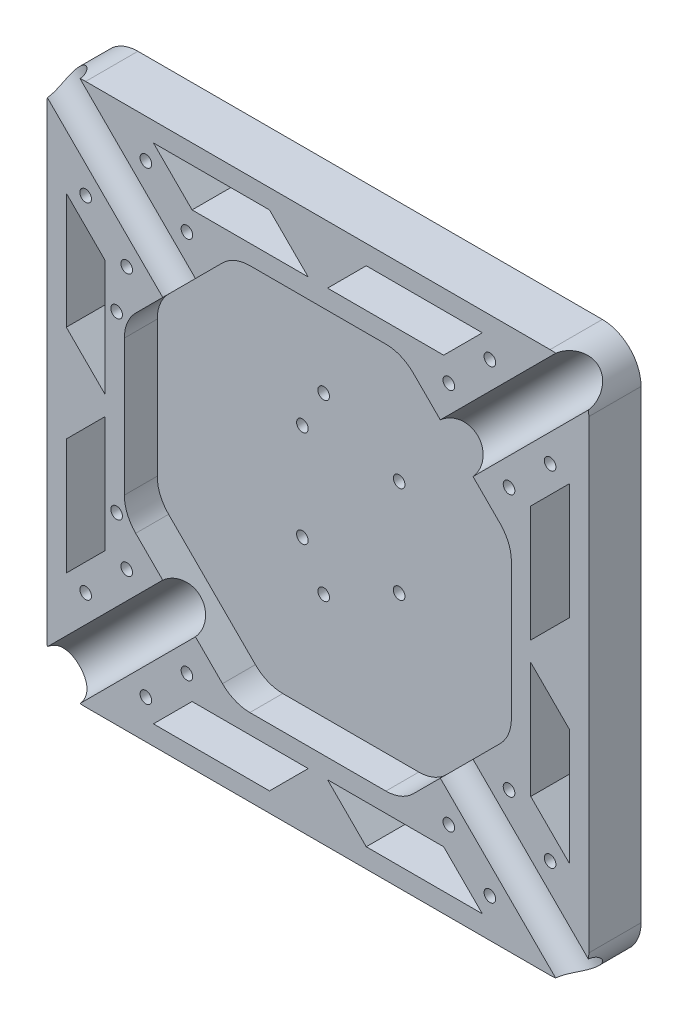
from build123d import *

# Parameters (mm, degrees)
ESQUISSE1_W                  = 140
ESQUISSE1_H                  = 140
BOSS_EXTRU_1_DEPTH           = 13.5
ENL_V_MAT_EXTRU_3_DEPTH      = 8.5
ENL_V_MAT_EXTRU_1_DEPTH      = 100
R_P_TITION_CIRCULAIRE1_COUNT = 2
R_P_TITION_CIRCULAIRE1_ANGLE = 90
CONG_1_R                     = 10
ESQUISSE3_R                  = 1.5
ENL_V_MAT_EXTRU_2_DEPTH      = 13.5
ENL_V_MAT_EXTRU_4_DEPTH      = 10
ENL_V_MAT_EXTRU_4_DEPTH_BACK = 12.5
ESQUISSE5_R                  = 1.5


with BuildPart() as part:
    # Esquisse1 → Boss.-Extru.1 (new body)
    with BuildSketch(Plane.XY):
        Rectangle(ESQUISSE1_W, ESQUISSE1_H)
        Polygon((65, 12.5), (55, 2.5), (55, 32.5), (65, 42.5), align=None, mode=Mode.SUBTRACT)
        Polygon((65, -12.5), (55, -2.5), (55, -32.5), (65, -42.5), align=None, mode=Mode.SUBTRACT)
        Polygon((12.5, -65), (2.5, -55), (32.5, -55), (42.5, -65), align=None, mode=Mode.SUBTRACT)
        Polygon((-12.5, -65), (-2.5, -55), (-32.5, -55), (-42.5, -65), align=None, mode=Mode.SUBTRACT)
        Polygon((-65, -12.5), (-55, -2.5), (-55, -32.5), (-65, -42.5), align=None, mode=Mode.SUBTRACT)
        Polygon((-65, 12.5), (-55, 2.5), (-55, 32.5), (-65, 42.5), align=None, mode=Mode.SUBTRACT)
        Polygon((-12.5, 65), (-2.5, 55), (-32.5, 55), (-42.5, 65), align=None, mode=Mode.SUBTRACT)
        Polygon((12.5, 65), (2.5, 55), (32.5, 55), (42.5, 65), align=None, mode=Mode.SUBTRACT)
    extrude(amount=BOSS_EXTRU_1_DEPTH)

    # Esquisse4 → Enlèv. mat.-Extru.3 (cut)
    with BuildSketch(Plane.XY.offset(13.5)):
        Polygon((-21.715728753, 50), (-50, 21.715728753), (-50, -21.715728753), (-21.715728753, -50), (21.715728753, -50), (50, -21.715728753), (50, 21.715728753), (21.715728753, 50), align=None)
    extrude(amount=-ENL_V_MAT_EXTRU_3_DEPTH, mode=Mode.SUBTRACT)

    # Esquisse2 → Enlèv. mat.-Extru.1 (cut, symmetric)
    with BuildSketch(Plane(origin=(0, 0, 0), x_dir=(-0.7071067811865475, -0.7071067811865477, 0), z_dir=(-0.7071067811865477, 0.7071067811865475, 0))):
        with BuildLine():
            Line((-6, 14), (6, 14))
            ThreePointArc((6, 14), (0, 8), (-6, 14))
        make_face()
    enl_v_mat_extru_1 = extrude(amount=ENL_V_MAT_EXTRU_1_DEPTH, both=True, mode=Mode.SUBTRACT)

    # Répétition circulaire1: Enlèv. mat.-Extru.1 ×2 about axis
    r_p_tition_circulaire1_axis = Axis((0, 0, -62.841973852), (0, 0, 1))
    for i in range(1, R_P_TITION_CIRCULAIRE1_COUNT):
        add(enl_v_mat_extru_1.rotate(r_p_tition_circulaire1_axis, i * R_P_TITION_CIRCULAIRE1_ANGLE / (R_P_TITION_CIRCULAIRE1_COUNT - 1)), mode=Mode.SUBTRACT)

    # Congé1
    cong_1_edges = [part.edges().sort_by_distance(p)[0] for p in [
        (-70, 70, 4),
        (-70, -70, 4),
        (70, 70, 4),
        (70, -70, 4),
        (-21.715728753, -50, 9.25),
        (21.715728753, -50, 9.25),
        (50, -21.715728753, 9.25),
        (50, 21.715728753, 9.25),
        (21.715728753, 50, 9.25),
        (-21.715728753, 50, 9.25),
        (-50, -21.715728753, 9.25),
        (-50, 21.715728753, 9.25),
    ]]
    fillet(cong_1_edges, radius=CONG_1_R)

    # Esquisse3 → Enlèv. mat.-Extru.2 (cut)
    with BuildSketch(Plane.XY.offset(13.5)):
        with Locations((-60, -44.443650814)):
            Circle(ESQUISSE3_R)
        with Locations((-44.443650814, -60)):
            Circle(ESQUISSE3_R)
        with Locations((-44.443650814, 60)):
            Circle(ESQUISSE3_R)
        with Locations((-60, 44.443650814)):
            Circle(ESQUISSE3_R)
        with Locations((60, 44.443650814)):
            Circle(ESQUISSE3_R)
        with Locations((44.443650814, 60)):
            Circle(ESQUISSE3_R)
        with Locations((44.443650814, -60)):
            Circle(ESQUISSE3_R)
        with Locations((60, -44.443650814)):
            Circle(ESQUISSE3_R)
    extrude(amount=-ENL_V_MAT_EXTRU_2_DEPTH, mode=Mode.SUBTRACT)

    # Esquisse5 → Enlèv. mat.-Extru.4 (cut, two sides: drawn at the far end of the back side and taken through both)
    with BuildSketch(Plane.XY.offset(5).offset(-ENL_V_MAT_EXTRU_4_DEPTH_BACK)):
        with Locations((-52, 22.5)):
            Circle(ESQUISSE5_R)
        with Locations((-7.000000025, 22.498488866)):
            Circle(ESQUISSE5_R)
        with Locations((-52.000000025, -22.5)):
            Circle(ESQUISSE5_R)
        with Locations((-7.000000025, -22.501511134)):
            Circle(ESQUISSE5_R)
        with Locations((-12.5, 12.5)):
            Circle(ESQUISSE5_R)
        with Locations((12.5, 12.5)):
            Circle(ESQUISSE5_R)
        with Locations((12.5, -12.5)):
            Circle(ESQUISSE5_R)
        with Locations((-12.5, -12.5)):
            Circle(ESQUISSE5_R)
        with Locations((33.837049096, 49.393398282)):
            Circle(ESQUISSE5_R)
        with Locations((49.393398282, 33.837049096)):
            Circle(ESQUISSE5_R)
        with Locations((49.393398282, -33.837049096)):
            Circle(ESQUISSE5_R)
        with Locations((33.837049096, -49.393398282)):
            Circle(ESQUISSE5_R)
        with Locations((-33.837049096, -49.393398282)):
            Circle(ESQUISSE5_R)
        with Locations((-49.393398282, -33.837049096)):
            Circle(ESQUISSE5_R)
        with Locations((-49.393398282, 33.837049096)):
            Circle(ESQUISSE5_R)
        with Locations((-33.837049096, 49.393398282)):
            Circle(ESQUISSE5_R)
    extrude(amount=ENL_V_MAT_EXTRU_4_DEPTH + ENL_V_MAT_EXTRU_4_DEPTH_BACK, mode=Mode.SUBTRACT)


solid = part.part
